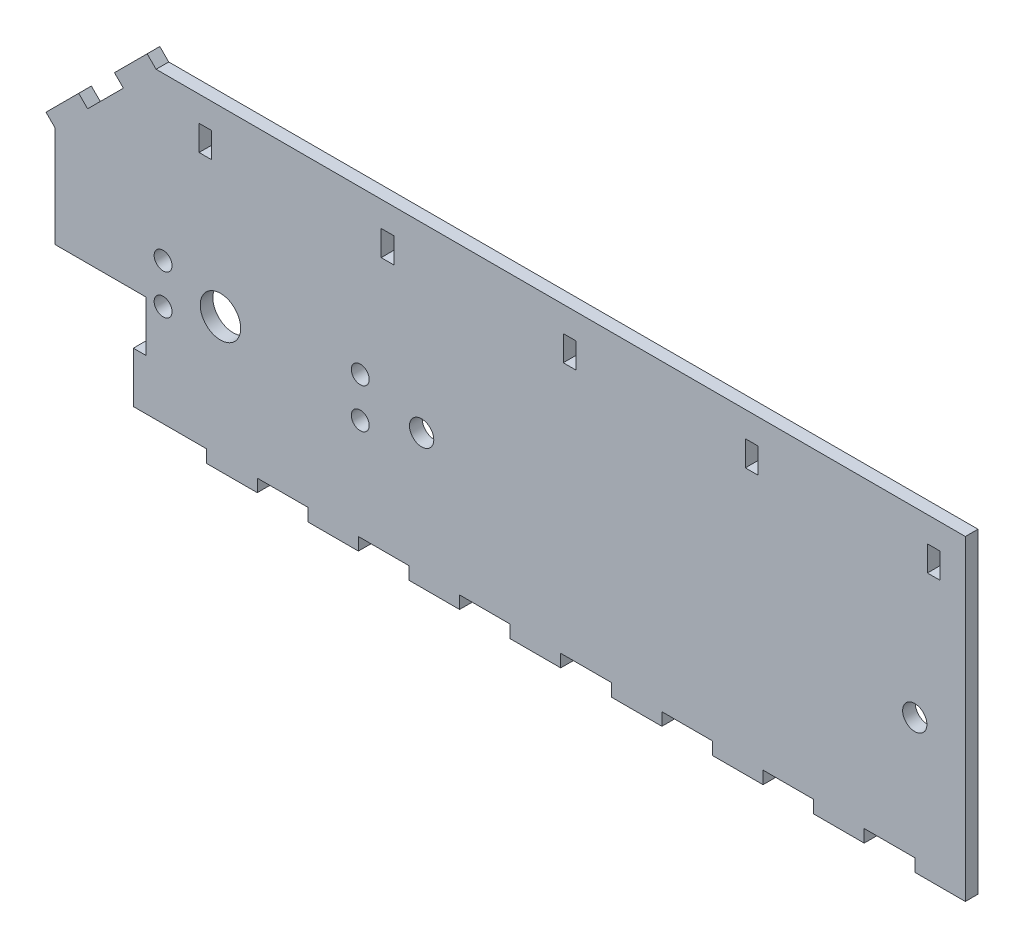
from build123d import *

# Parameters (mm, degrees)
SKETCH1_W           = 228.6
SKETCH1_H           = 76.2
SKETCH1_R           = 3.048
SKETCH1_R_2         = 5.08
BOSS_EXTRUDE1_DEPTH = 3.175
SKETCH2_W           = 12.7
SKETCH2_H           = 3.175
BOSS_EXTRUDE2_DEPTH = 3.175
SKETCH3_W           = 22.86
SKETCH3_H           = 25.4
CUT_EXTRUDE1_DEPTH  = 4.175
SKETCH4_W           = 3.175
SKETCH4_H           = 12.7
BOSS_EXTRUDE3_DEPTH = 3.175
SKETCH6_R           = 2.25
CUT_EXTRUDE2_DEPTH  = 4.175
CUT_EXTRUDE3_DEPTH  = 4.175
SKETCH12_W          = 3.175
SKETCH12_H          = 6.35
CUT_EXTRUDE5_DEPTH  = 3.175
SKETCH13_W          = 3.175
SKETCH13_H          = 11.610512243
SKETCH13_H_2        = 11.610512242
BOSS_EXTRUDE5_DEPTH = 3.175


with BuildPart() as part:
    # Sketch1 → Boss-Extrude1 (new body)
    with BuildSketch(Plane.XY):
        with Locations((114.3, 38.1)):
            Rectangle(SKETCH1_W, SKETCH1_H)
        with Locations((215.9, 30.48)):
            Circle(SKETCH1_R, mode=Mode.SUBTRACT)
        with Locations((92.075, 30.48)):
            Circle(SKETCH1_R, mode=Mode.SUBTRACT)
        with Locations((41.56075, 30.48)):
            Circle(SKETCH1_R_2, mode=Mode.SUBTRACT)
    extrude(amount=BOSS_EXTRUDE1_DEPTH)

    # Sketch2 → Boss-Extrude2 (add)
    with BuildSketch(Plane.XZ):
        with Locations((222.25, 1.5875)):
            Rectangle(SKETCH2_W, SKETCH2_H)
        with Locations((196.85, 1.5875)):
            Rectangle(SKETCH2_W, SKETCH2_H)
        with Locations((171.45, 1.5875)):
            Rectangle(SKETCH2_W, SKETCH2_H)
        with Locations((146.05, 1.5875)):
            Rectangle(SKETCH2_W, SKETCH2_H)
        with Locations((120.65, 1.5875)):
            Rectangle(SKETCH2_W, SKETCH2_H)
        with Locations((95.25, 1.5875)):
            Rectangle(SKETCH2_W, SKETCH2_H)
        with Locations((69.85, 1.5875)):
            Rectangle(SKETCH2_W, SKETCH2_H)
        with Locations((44.45, 1.5875)):
            Rectangle(SKETCH2_W, SKETCH2_H)
    extrude(amount=BOSS_EXTRUDE2_DEPTH)

    # Sketch3 → Cut-Extrude1 (cut, through all)
    with BuildSketch(Plane(origin=(0, 0, 0), x_dir=(-1, 0, 0), z_dir=(0, 0, -1))):
        with Locations((-11.43, 12.7)):
            Rectangle(SKETCH3_W, SKETCH3_H)
    extrude(amount=-CUT_EXTRUDE1_DEPTH, mode=Mode.SUBTRACT)

    # Sketch4 → Boss-Extrude3 (add)
    with BuildSketch(Plane.ZY.offset(-22.86)):
        with Locations((1.5875, 6.35)):
            Rectangle(SKETCH4_W, SKETCH4_H)
    extrude(amount=BOSS_EXTRUDE3_DEPTH)

    # Sketch6 → Cut-Extrude2 (cut, through all)
    with BuildSketch(Plane(origin=(0, 0, 0), x_dir=(-1, 0, 0), z_dir=(0, 0, -1))):
        with Locations((-27.16075, 35.48)):
            Circle(SKETCH6_R)
        with Locations((-27.16075, 25.48)):
            Circle(SKETCH6_R)
        with Locations((-76.66075, 35.48)):
            Circle(SKETCH6_R)
        with Locations((-76.66075, 25.48)):
            Circle(SKETCH6_R)
    extrude(amount=-CUT_EXTRUDE2_DEPTH, mode=Mode.SUBTRACT)

    # Sketch8 → Cut-Extrude3 (cut, through all)
    with BuildSketch(Plane.XY.offset(3.175)):
        Polygon((25.4, 76.2), (0, 76.2), (0, 50.8), align=None)
    extrude(amount=-CUT_EXTRUDE3_DEPTH, mode=Mode.SUBTRACT)

    # Sketch12 → Cut-Extrude5 (cut)
    with BuildSketch(Plane(origin=(0, 0, 0), x_dir=(-1, 0, 0), z_dir=(0, 0, -1))):
        with Locations((-220.6625, 66.675)):
            Rectangle(SKETCH12_W, SKETCH12_H)
        with Locations((-174.9425, 66.675)):
            Rectangle(SKETCH12_W, SKETCH12_H)
        with Locations((-129.2225, 66.675)):
            Rectangle(SKETCH12_W, SKETCH12_H)
        with Locations((-83.5025, 66.675)):
            Rectangle(SKETCH12_W, SKETCH12_H)
        with Locations((-37.7825, 66.675)):
            Rectangle(SKETCH12_W, SKETCH12_H)
    extrude(amount=-CUT_EXTRUDE5_DEPTH, mode=Mode.SUBTRACT)

    # Sketch13 → Boss-Extrude5 (add)
    with BuildSketch(Plane(origin=(-25.4, 25.4, 0), x_dir=(0, 0, 1), z_dir=(-0.707106781, 0.707106781, 0))):
        with Locations((1.5875, 66.036792848)):
            Rectangle(SKETCH13_W, SKETCH13_H)
        with Locations((1.5875, 41.726280605)):
            Rectangle(SKETCH13_W, SKETCH13_H_2)
    extrude(amount=BOSS_EXTRUDE5_DEPTH)


solid = part.part
